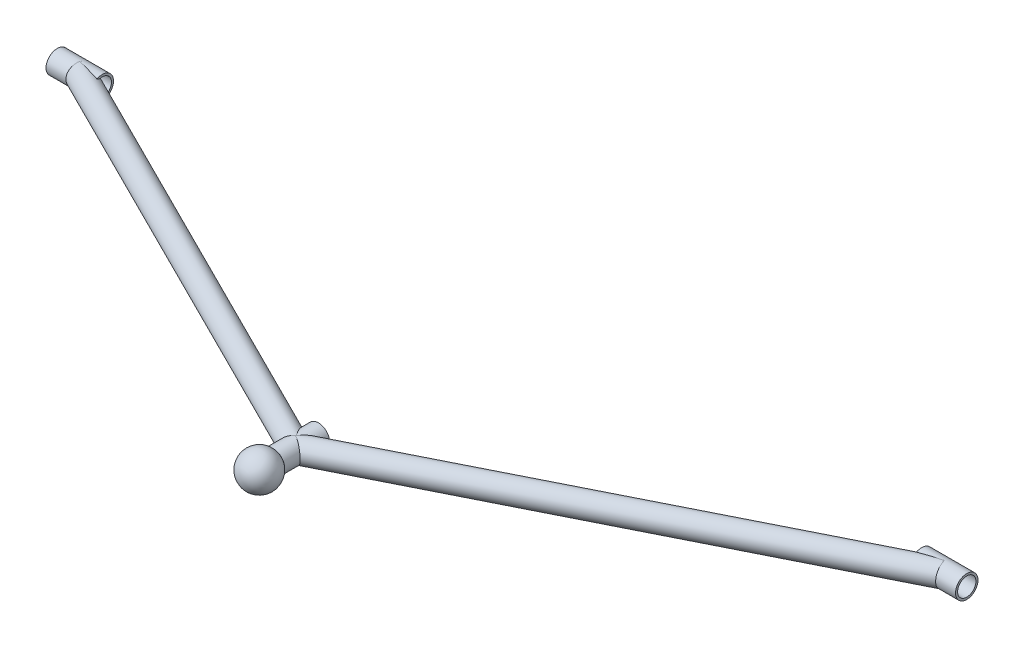
from build123d import *

# Parameters (mm, degrees)
SKETCH11_R                                     = 7.9375
SKETCH11_R_2                                   = 6.4643
AL_ROUND_TUBING_AL_RND_TUBE_0_625_OD_X_0_DEPTH = 347.389419847
SKETCH11_ON_SEGMENT_2_R                        = 7.9375
SKETCH11_ON_SEGMENT_2_R_2                      = 6.4643
AL_ROUND_TUBING_AL_RND_TUBE_0_625_OD_3_DEPTH   = 347.389419847
SKETCH12_R                                     = 7.9375
SKETCH12_R_2                                   = 6.4643
AL_ROUND_TUBING_AL_RND_TUBE_0_625_OD_4_DEPTH   = 31.75
SKETCH12_ON_SEGMENT_2_R                        = 7.9375
SKETCH12_ON_SEGMENT_2_R_2                      = 6.4643
AL_ROUND_TUBING_AL_RND_TUBE_0_625_OD_4_2_DEPTH = 31.75
SKETCH12_ON_SEGMENT_3_R                        = 7.9375
SKETCH12_ON_SEGMENT_3_R_2                      = 6.4643
AL_ROUND_TUBING_AL_RND_TUBE_0_625_OD_4_3_DEPTH = 31.75


with BuildPart() as part:
    # Sketch11 → Al round tubing AL RND TUBE 0.625 OD X 0 (new body)
    with BuildSketch(Plane(origin=(-304.8, 0, 0), x_dir=(0.447213595499958, 0, -0.894427190999916), z_dir=(0.894427190999916, 0, 0.447213595499958))):
        Circle(SKETCH11_R)
        Circle(SKETCH11_R_2, mode=Mode.SUBTRACT)
    extrude(amount=AL_ROUND_TUBING_AL_RND_TUBE_0_625_OD_X_0_DEPTH)

    # Al round tubing AL RND TUBE 0.625 OD 2
    split(bisect_by=Plane(origin=(0, 0, 152.4), x_dir=(0, -1, 0), z_dir=(-1, 0, 0)), keep=Keep.TOP)


with BuildPart() as body_2:
    # Sketch11 on segment 2 (carried to segment 2) → Al round tubing AL RND TUBE 0.625 OD 3 (new body)
    with BuildSketch(Plane(origin=(-5.914542977, 0, 155.357271488), x_dir=(-0.447213595, 0, -0.894427191), z_dir=(0.894427191, 0, -0.447213595))):
        Circle(SKETCH11_ON_SEGMENT_2_R)
        Circle(SKETCH11_ON_SEGMENT_2_R_2, mode=Mode.SUBTRACT)
    extrude(amount=AL_ROUND_TUBING_AL_RND_TUBE_0_625_OD_3_DEPTH)

    # Al round tubing AL RND TUBE 0.625 OD 3 m
    split(bisect_by=Plane(origin=(0, 0, 152.4), x_dir=(0, 1, 0), z_dir=(1, 0, 0)), keep=Keep.TOP)


with BuildPart() as body_3:
    # Sketch12 → Al round tubing AL RND TUBE 0.625 OD 4 (new body)
    with BuildSketch(Plane.XY.offset(136.525)):
        Circle(SKETCH12_R)
        Circle(SKETCH12_R_2, mode=Mode.SUBTRACT)
    extrude(amount=AL_ROUND_TUBING_AL_RND_TUBE_0_625_OD_4_DEPTH)


with BuildPart() as body_4:
    # Sketch12 on segment 2 (carried to segment 2) → Al round tubing AL RND TUBE 0.625 OD 4 2 (new body)
    with BuildSketch(Plane.ZY.offset(288.925)):
        Circle(SKETCH12_ON_SEGMENT_2_R)
        Circle(SKETCH12_ON_SEGMENT_2_R_2, mode=Mode.SUBTRACT)
    extrude(amount=AL_ROUND_TUBING_AL_RND_TUBE_0_625_OD_4_2_DEPTH)


with BuildPart() as body_5:
    # Sketch12 on segment 3 (carried to segment 3) → Al round tubing AL RND TUBE 0.625 OD 4 3 (new body)
    with BuildSketch(Plane(origin=(288.925, 0, 0), x_dir=(0, 0, -1), z_dir=(1, 0, 0))):
        Circle(SKETCH12_ON_SEGMENT_3_R)
        Circle(SKETCH12_ON_SEGMENT_3_R_2, mode=Mode.SUBTRACT)
    extrude(amount=AL_ROUND_TUBING_AL_RND_TUBE_0_625_OD_4_3_DEPTH)


with BuildPart() as body_6:
    # Sketch13 → Revolve1 (revolve)
    with BuildSketch(Plane(origin=(0, 0, 0), x_dir=(0, 0, -1), z_dir=(1, 0, 0))):
        with BuildLine():
            Line((-165.488934322, 0), (-190.888934322, 0))
            ThreePointArc((-190.888934322, 0), (-178.188934322, 12.7), (-165.488934322, 0))
        make_face()
    revolve(axis=Axis((0, 0, 165.488934322), (0, 0, 1)))


solid = Compound([part.part, body_2.part, body_3.part, body_4.part, body_5.part, body_6.part])
